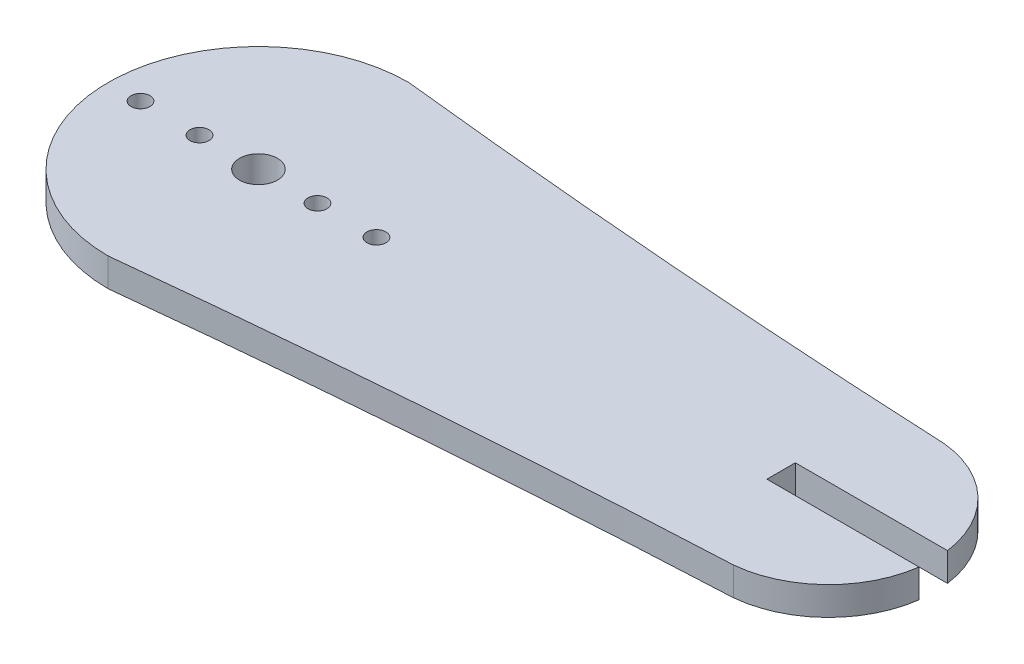
from build123d import *

# Parameters (mm, degrees)
SKETCH1_R           = 1
SKETCH1_R_2         = 2
BOSS_EXTRUDE1_DEPTH = 3


with BuildPart() as part:
    # Sketch1 → Boss-Extrude1 (new body)
    with BuildSketch(Plane(origin=(0, 0, 0), x_dir=(1, 0, 0), z_dir=(0, 1, 0))):
        with BuildLine():
            Line((64.190973866, -16.340444348), (48.133067619, -16.340444348))
            Line((48.133067619, -16.340444348), (48.133067619, -13.340444349))
            Line((48.133067619, -13.340444349), (64.190973866, -13.340444349))
            ThreePointArc((64.190973866, -13.340444349), (60.864318365, -6.794408764), (54.189826358, -3.733628612))
            ThreePointArc((54.189826358, -3.733628612), (53.662670154, -3.708804342), (53.135527124, -3.683701873))
            ThreePointArc((53.135527124, -3.683701873), (24.702146142, -1.915932839), (-3.669341235, 0.661054823))
            ThreePointArc((-3.669341235, 0.661054823), (-5.346030709, 0.838891836), (-7.022417949, 1.019555652))
            ThreePointArc((-7.022417949, 1.019555652), (-22.882417949, -14.840444348), (-7.022417949, -30.700444348))
            ThreePointArc((-7.022417949, -30.700444348), (-5.346030709, -30.519780533), (-3.669341235, -30.341943519))
            ThreePointArc((-3.669341235, -30.341943519), (24.702146142, -27.764955858), (53.135527124, -25.997186824))
            ThreePointArc((53.135527124, -25.997186824), (53.662670154, -25.972084355), (54.189826358, -25.947260084))
            ThreePointArc((54.189826358, -25.947260084), (60.864318365, -22.886479933), (64.190973866, -16.340444348))
        make_face()
        with Locations((-19.472417949, -14.840444348)):
            Circle(SKETCH1_R, mode=Mode.SUBTRACT)
        with Locations((-13.247417949, -14.840444348)):
            Circle(SKETCH1_R, mode=Mode.SUBTRACT)
        with Locations((-7.022417949, -14.840444348)):
            Circle(SKETCH1_R_2, mode=Mode.SUBTRACT)
        with Locations((-0.797417949, -14.840444348)):
            Circle(SKETCH1_R, mode=Mode.SUBTRACT)
        with Locations((5.427582051, -14.840444348)):
            Circle(SKETCH1_R, mode=Mode.SUBTRACT)
    extrude(amount=BOSS_EXTRUDE1_DEPTH)


solid = part.part
